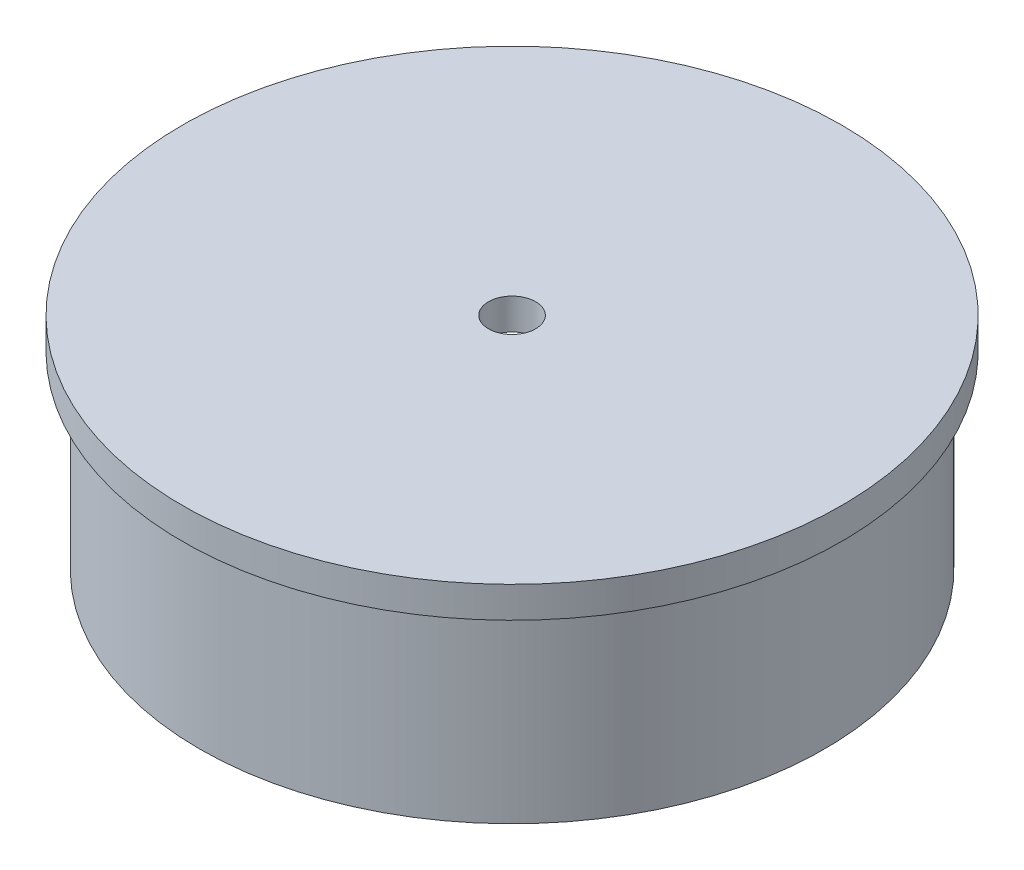
from build123d import *

# Parameters (mm, degrees)
SKETCH3_R = 2.38125
FILLET1_R = 1.27


with BuildPart() as part:
    # Sketch1 → Revolve1 (revolve)
    with BuildSketch(Plane.XY):
        with BuildLine():
            Line((-21.0693, -14.8), (-21.0693, -2.1))
            Line((-21.0693, -2.1), (-22.225, -2.1))
            Line((-22.225, -2.1), (-22.225, 0))
            Line((-22.225, 0), (-1.5875, 0))
            Line((-1.5875, 0), (-1.5875, -2.1))
            Line((-1.5875, -2.1), (-17.4879, -2.1))
            ThreePointArc((-17.4879, -2.1), (-19.283951224, -2.843948776), (-20.0279, -4.64))
            Line((-20.0279, -4.64), (-20.0279, -14.8))
            Line((-20.0279, -14.8), (-21.0693, -14.8))
        make_face()
    revolve(axis=Axis((0, 0, 0), (0, 1, 0)))

    # Sweep1: sweep along a path in Sketch2
    with BuildLine(Plane.XY.offset(-9.525)) as sweep1_path:
        Line((-1.5875, -2.1), (-1.5875, -4.555166767))
        ThreePointArc((-1.5875, -4.555166767), (0, -6.142666767), (1.5875, -4.555166767))
        Line((1.5875, -4.555166767), (1.5875, -2.1))
    # Sketch3 → Sweep1 (sweep)
    with BuildSketch(Plane.XZ.offset(2.1)):
        with Locations((4.702681807, -9.525)):
            Circle(SKETCH3_R)
    sweep1 = sweep(path=sweep1_path.line)

    # Fillet1
    fillet1_edges = [part.edges().sort_by_distance(p)[0] for p in [
        (2.321431807, -2.1, -9.525),
        (-2.321431807, -2.1, -9.525),
    ]]
    fillet(fillet1_edges, radius=FILLET1_R)

    # Mirror1: Sweep1 across plane
    add(sweep1.mirror(Plane.XY))


solid = part.part
